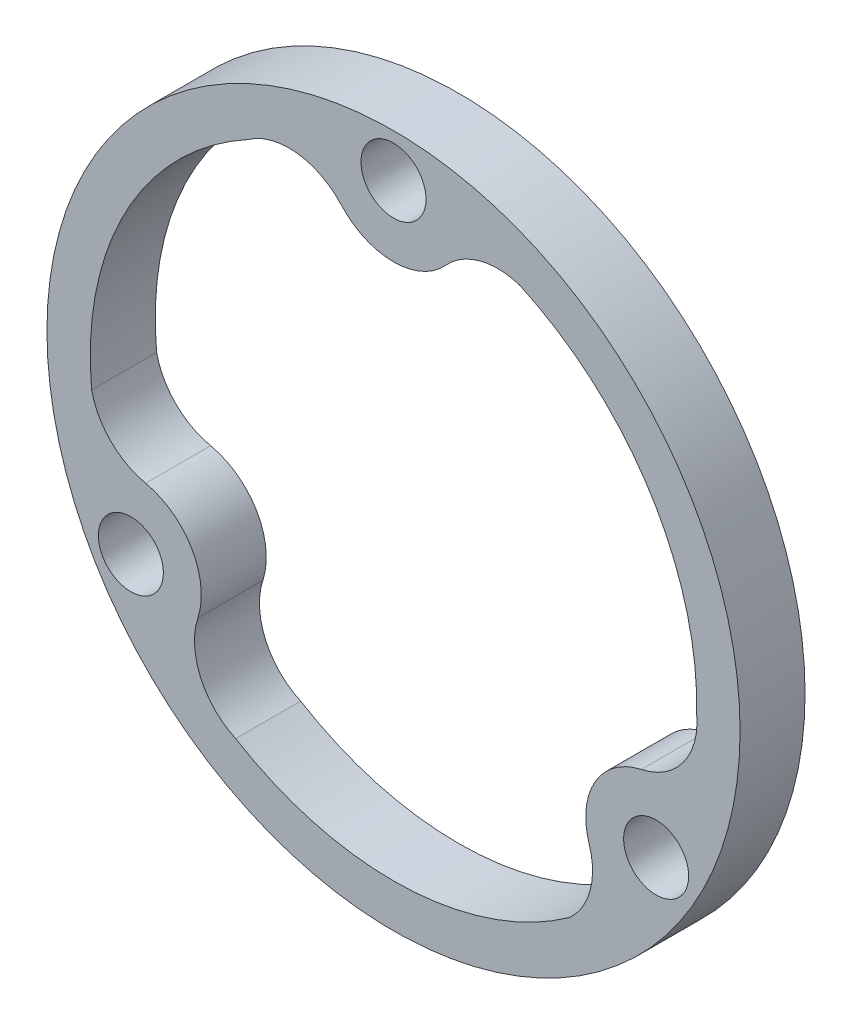
from build123d import *

# Parameters (mm, degrees)
ESQUISSE1_R        = 16
ESQUISSE1_R_2      = 1.5
BOSS_EXTRU_2_DEPTH = 3


with BuildPart() as part:
    # Esquisse1 → Boss.-Extru.2 (new body)
    with BuildSketch(Plane.XY):
        Circle(ESQUISSE1_R)
        with Locations((0, 14)):
            Circle(ESQUISSE1_R_2, mode=Mode.SUBTRACT)
        with Locations((12.124355653, -7)):
            Circle(ESQUISSE1_R_2, mode=Mode.SUBTRACT)
        with Locations((-12.124355653, -7)):
            Circle(ESQUISSE1_R_2, mode=Mode.SUBTRACT)
        with BuildLine():
            ThreePointArc((-2.411034891, 11.820685714), (0, 10.75), (2.411034891, 11.820685714))
            ThreePointArc((2.411034891, 11.820685714), (3.975330286, 12.779130538), (5.80943088, 12.737759334))
            ThreePointArc((5.80943088, 12.737759334), (11.865562564, 7.430237213), (13.995977593, -0.335575935))
            ThreePointArc((13.995977593, -0.335575935), (13.382779595, -2.564868949), (11.442531564, -3.822325392))
            ThreePointArc((11.442531564, -3.822325392), (9.309773091, -5.375), (9.031496673, -7.998360322))
            ThreePointArc((9.031496673, -7.998360322), (9.079386541, -9.832302285), (8.126507731, -11.399994391))
            ThreePointArc((8.126507731, -11.399994391), (0.5019929, -13.990997217), (-7.288606081, -11.953084179))
            ThreePointArc((-7.288606081, -11.953084179), (-8.912631465, -10.307392628), (-9.031496673, -7.998360322))
            ThreePointArc((-9.031496673, -7.998360322), (-9.309773091, -5.375), (-11.442531564, -3.822325392))
            ThreePointArc((-11.442531564, -3.822325392), (-13.054716827, -2.946828253), (-13.935938611, -1.337764944))
            ThreePointArc((-13.935938611, -1.337764944), (-12.367555464, 6.560760004), (-6.707371512, 12.288660114))
            ThreePointArc((-6.707371512, 12.288660114), (-4.47014813, 12.872261577), (-2.411034891, 11.820685714))
        make_face(mode=Mode.SUBTRACT)
    extrude(amount=BOSS_EXTRU_2_DEPTH)


solid = part.part
